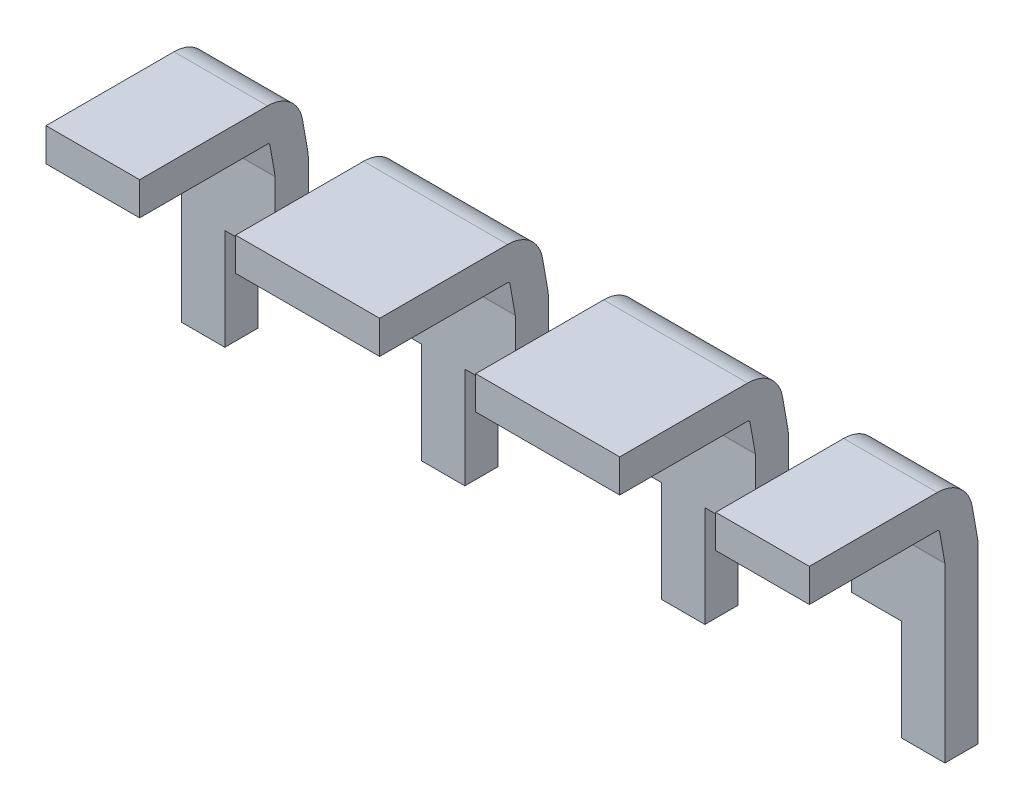
from build123d import *

# Parameters (mm, degrees)
SKETCH1_W      = 1.524
SKETCH1_H      = 0.35
SKETCH1_W_2    = 0.9906
SKETCH10_W     = 0.5334
SKETCH10_H     = 1.114856468
EXTRUDE1_DEPTH = 3.08092137


with BuildPart() as part:
    # Sweep11: sweep along a path in Sketch2
    with BuildLine(Plane(origin=(0, 0, 0), x_dir=(0, 0, -1), z_dir=(1, 0, 0))) as sweep11_path:
        Line((0, 0), (1.354016583, 0))
        ThreePointArc((1.354016583, 0), (1.482574105, -0.046791111), (1.550978134, -0.165270364))
        Line((1.550978134, -0.165270364), (1.606961551, -0.482768097))
        ThreePointArc((1.606961551, -0.482768097), (1.60923894, -0.500066584), (1.61, -0.517497733))
        Line((1.61, -0.517497733), (1.61, -2.345))
    # Sketch1 → Sweep11 (sweep)
    with BuildSketch(Plane.XY):
        with Locations((-1.27, 0)):
            Rectangle(SKETCH1_W, SKETCH1_H)
        with Locations((1.27, 0)):
            Rectangle(SKETCH1_W, SKETCH1_H)
        with Locations((3.5433, 0)):
            Rectangle(SKETCH1_W_2, SKETCH1_H)
        with Locations((-3.5433, 0)):
            Rectangle(SKETCH1_W_2, SKETCH1_H)
    sweep(path=sweep11_path.line)

    # Sketch10 → Extrude1 (cut, through all)
    with BuildSketch(Plane(origin=(0, 0.290637802, -1.648288881), x_dir=(-1, 0, 0), z_dir=(0, 0.173648178, -0.984807753))):
        with Locations((-3.3147, -2.061907944)):
            Rectangle(SKETCH10_W, SKETCH10_H)
        with Locations((-1.7653, -2.061907944)):
            Rectangle(SKETCH10_W, SKETCH10_H)
        with Locations((-0.7747, -2.061907944)):
            Rectangle(SKETCH10_W, SKETCH10_H)
        with Locations((0.7747, -2.061907944)):
            Rectangle(SKETCH10_W, SKETCH10_H)
        with Locations((1.7653, -2.061907944)):
            Rectangle(SKETCH10_W, SKETCH10_H)
        with Locations((3.3147, -2.061907944)):
            Rectangle(SKETCH10_W, SKETCH10_H)
    extrude(amount=-EXTRUDE1_DEPTH, mode=Mode.SUBTRACT)


solid = part.part
